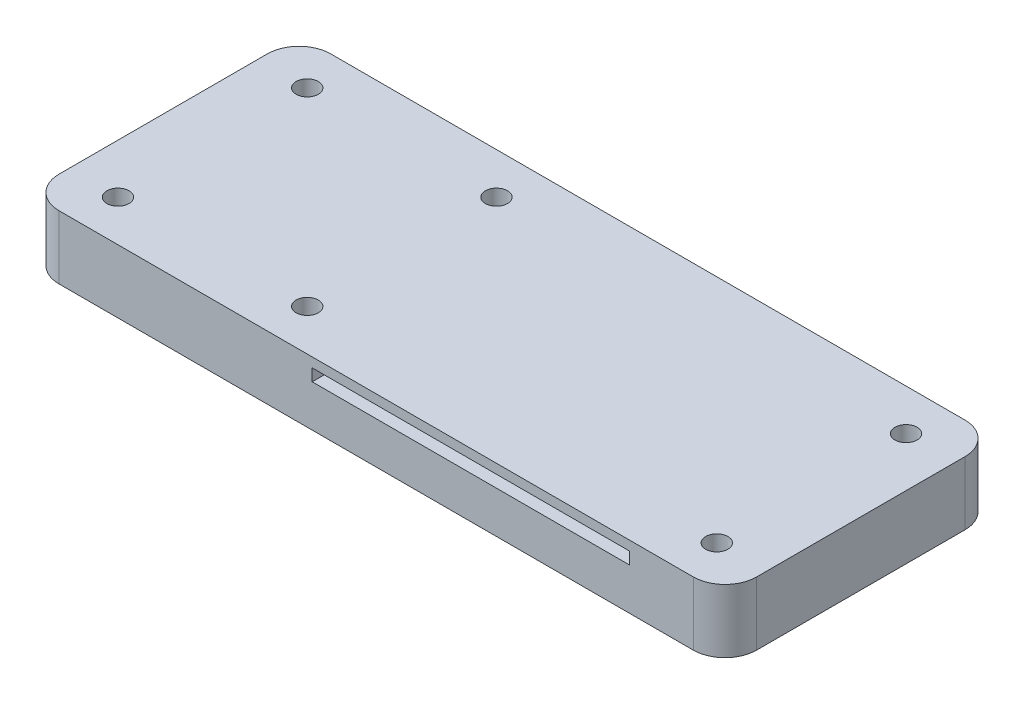
from build123d import *

# Parameters (mm, degrees)
SKETCH1_R           = 1.75
BOSS_EXTRUDE1_DEPTH = 5
SKETCH2_W           = 50
SKETCH2_H           = 1.9
CUT_EXTRUDE1_DEPTH  = 43.84


with BuildPart() as part:
    # Sketch1 → Boss-Extrude1 (new body, symmetric)
    with BuildSketch(Plane(origin=(0, 0, 0), x_dir=(1, 0, 0), z_dir=(0, 1, 0))):
        with BuildLine():
            Line((-50, -21.42), (50, -21.42))
            ThreePointArc((50, -21.42), (53.535533906, -19.955533906), (55, -16.42))
            Line((55, -16.42), (55, 16.42))
            ThreePointArc((55, 16.42), (53.535533906, 19.955533906), (50, 21.42))
            Line((50, 21.42), (-50, 21.42))
            ThreePointArc((-50, 21.42), (-53.535533906, 19.955533906), (-55, 16.42))
            Line((-55, 16.42), (-55, -16.42))
            ThreePointArc((-55, -16.42), (-53.535533906, -19.955533906), (-50, -21.42))
        make_face()
        with Locations((-47.209953083, 14.919953083)):
            Circle(SKETCH1_R, mode=Mode.SUBTRACT)
        with Locations((-17.370046917, 14.919953083)):
            Circle(SKETCH1_R, mode=Mode.SUBTRACT)
        with Locations((-17.370046917, -14.919953083)):
            Circle(SKETCH1_R, mode=Mode.SUBTRACT)
        with Locations((-47.209953083, -14.919953083)):
            Circle(SKETCH1_R, mode=Mode.SUBTRACT)
        with Locations((47.209953083, 14.919953083)):
            Circle(SKETCH1_R, mode=Mode.SUBTRACT)
        with Locations((47.209953083, -14.919953083)):
            Circle(SKETCH1_R, mode=Mode.SUBTRACT)
    extrude(amount=BOSS_EXTRUDE1_DEPTH, both=True)

    # Sketch2 → Cut-Extrude1 (cut, through all)
    with BuildSketch(Plane.XY.offset(21.42)):
        with Locations((14.919953083, 2.55)):
            Rectangle(SKETCH2_W, SKETCH2_H)
    extrude(amount=-CUT_EXTRUDE1_DEPTH, mode=Mode.SUBTRACT)


solid = part.part
